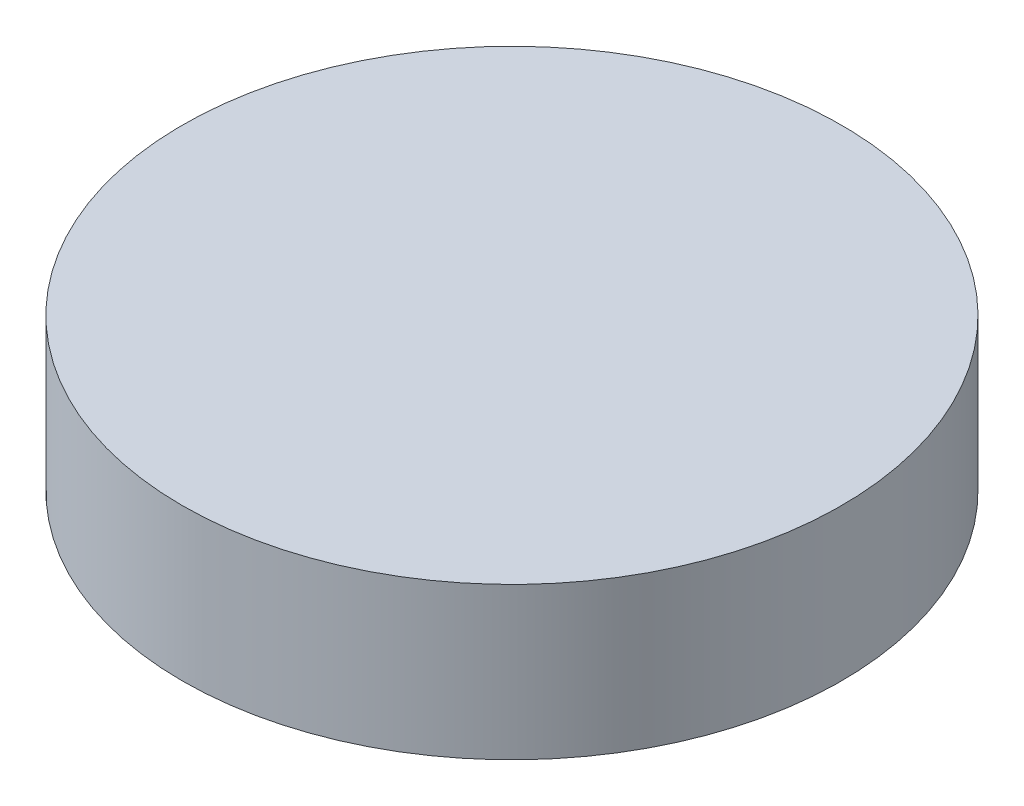
from build123d import *

# Parameters (mm, degrees)
SKETCH2_R           = 5.425
BOSS_EXTRUDE1_DEPTH = 2.5


with BuildPart() as part:
    # Sketch2 → Boss-Extrude1 (new body)
    with BuildSketch(Plane(origin=(0, 53, 0), x_dir=(1, 0, 0), z_dir=(0, 1, 0))):
        with Locations((-27.5, 11.5)):
            Circle(SKETCH2_R)
    extrude(amount=-BOSS_EXTRUDE1_DEPTH)


solid = part.part
